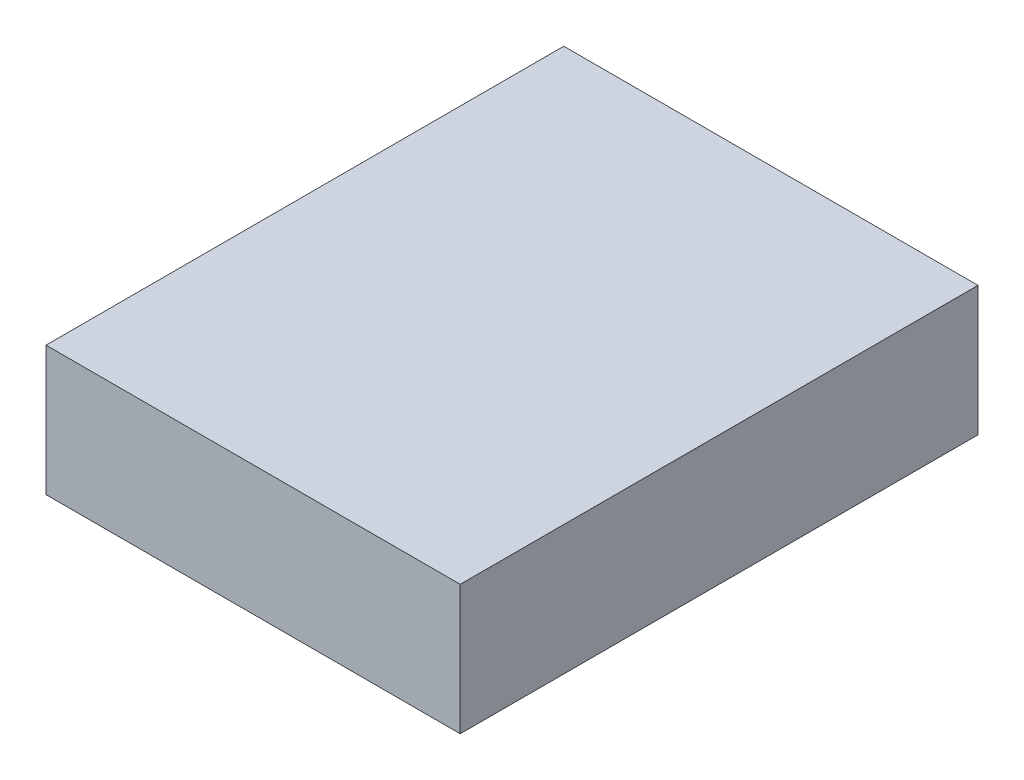
from build123d import *

# Parameters (mm, degrees)
SKETCH1_W           = 406.4
SKETCH1_H           = 127
BOSS_EXTRUDE1_DEPTH = 508


with BuildPart() as part:
    # Sketch1 → Boss-Extrude1 (new body)
    with BuildSketch(Plane.XY):
        with Locations((203.2, 63.5)):
            Rectangle(SKETCH1_W, SKETCH1_H)
    extrude(amount=BOSS_EXTRUDE1_DEPTH)


solid = part.part
